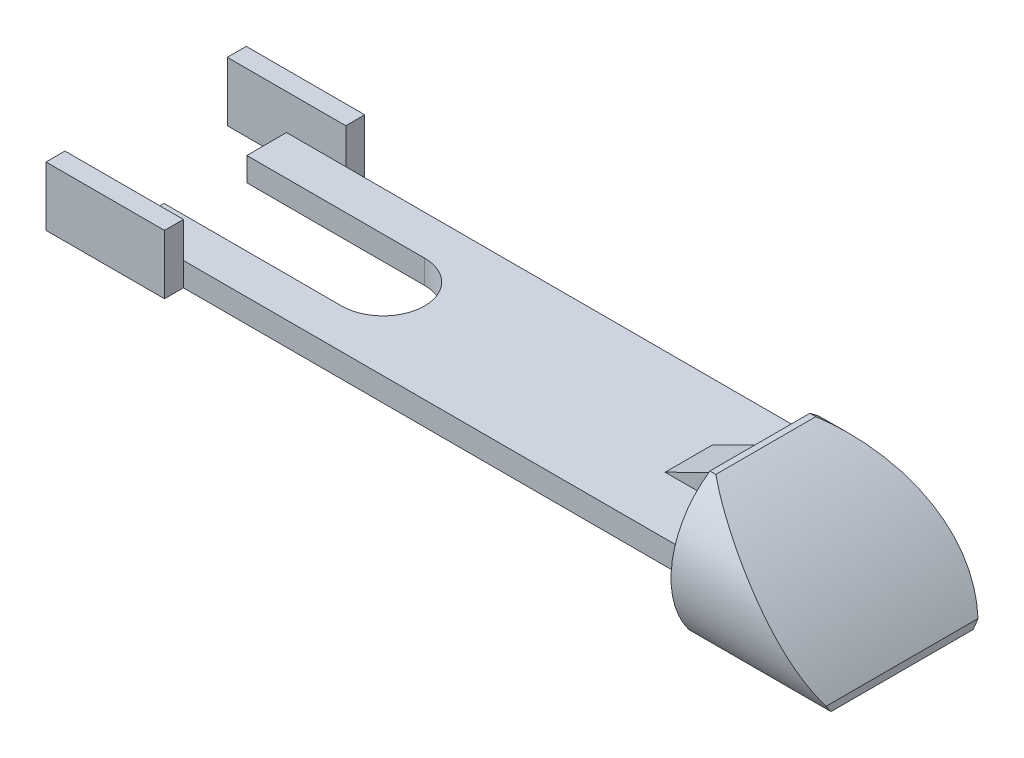
from build123d import *

# Parameters (mm, degrees)
SKETCH1_W               = 59.436
SKETCH1_H               = 17.399
BOSS_EXTRUDE1_DEPTH     = 2.54
CUT_EXTRUDE1_DEPTH      = 32.069155512
SKETCH3_W               = 12.7
SKETCH3_H               = 6.35
BOSS_EXTRUDE2_DEPTH     = 2.032
BOSS_EXTRUDE3_DEPTH     = 15.24
CUT_EXTRUDE2_DEPTH      = 47.886984472
CUT_EXTRUDE2_DEPTH_BACK = 47.886984472
RIB1_REACH              = 48.887
SKETCH6_WALL_W          = 104.28296917
SKETCH6_WALL_H          = 5.08


with BuildPart() as part:
    # Sketch1 → Boss-Extrude1 (new body)
    with BuildSketch(Plane(origin=(0, 0, 0), x_dir=(1, 0, 0), z_dir=(0, 1, 0))):
        Rectangle(SKETCH1_W, SKETCH1_H)
    extrude(amount=BOSS_EXTRUDE1_DEPTH)

    # Sketch2 → Cut-Extrude1 (cut, through all)
    with BuildSketch(Plane(origin=(0, 2.54, 0), x_dir=(1, 0, 0), z_dir=(0, 1, 0))):
        with BuildLine():
            Line((-29.718, 0), (-29.718, 4.445))
            Line((-29.718, 4.445), (-10.668, 4.445))
            ThreePointArc((-10.668, 4.445), (-6.223, 0), (-10.668, -4.445))
            Line((-10.668, -4.445), (-29.718, -4.445))
            Line((-29.718, -4.445), (-29.718, 0))
        make_face()
    extrude(amount=-CUT_EXTRUDE1_DEPTH, mode=Mode.SUBTRACT)

    # Sketch3 → Boss-Extrude2 (add)
    with BuildSketch(Plane.XY.offset(8.6995)):
        with Locations((-29.718, 3.175)):
            Rectangle(SKETCH3_W, SKETCH3_H)
    boss_extrude2 = extrude(amount=BOSS_EXTRUDE2_DEPTH)

    # Mirror1: Boss-Extrude2 across plane
    add(boss_extrude2.mirror(Plane.XY))

    # Sketch4 → Boss-Extrude3 (add)
    with BuildSketch(Plane(origin=(29.718, 0, 0), x_dir=(0, 0, -1), z_dir=(1, 0, 0))):
        with BuildLine():
            Line((-5.3594, 7.874163869), (5.3594, 7.874163869))
            ThreePointArc((5.3594, 7.874163869), (9.395879403, 1.563033987), (7.62, -5.715))
            Line((7.62, -5.715), (-7.62, -5.715))
            ThreePointArc((-7.62, -5.715), (-9.395879403, 1.563033987), (-5.3594, 7.874163869))
        make_face()
    extrude(amount=BOSS_EXTRUDE3_DEPTH)

    # Sketch5 → Cut-Extrude2 (cut, two sides)
    with BuildSketch(Plane.XY) as cut_extrude2_sk:
        with BuildLine():
            Line((-125.410978847, 85.578603758), (30.353, 7.874163869))
            ThreePointArc((30.353, 7.874163869), (38.487292522, 2.407660331), (44.958, -4.953))
            Line((44.958, -4.953), (142.117632376, -149.38430866))
            Line((142.117632376, -149.38430866), (371.853916425, 112.19326708))
            Line((371.853916425, 112.19326708), (104.325305202, 347.156179498))
            Line((104.325305202, 347.156179498), (-125.410978847, 85.578603758))
        make_face()
    extrude(amount=CUT_EXTRUDE2_DEPTH, mode=Mode.SUBTRACT)
    extrude(cut_extrude2_sk.sketch, amount=-CUT_EXTRUDE2_DEPTH_BACK, mode=Mode.SUBTRACT)

    # Sketch6 wall → Rib1 (add, up to next)
    with BuildSketch(Plane(origin=(25.908, 4.433322543, 0), x_dir=(0.895522388061, 0.445016463157, 0), z_dir=(-0.445016463157, 0.895522388061, 0)), mode=Mode.PRIVATE) as rib1_sk1:
        Rectangle(SKETCH6_WALL_W, SKETCH6_WALL_H)
    rib1_tool1 = extrude(rib1_sk1.sketch, amount=-RIB1_REACH, mode=Mode.PRIVATE) - part.part
    add(rib1_tool1.solids().sort_by_distance((25.908, 4.433322543, 0))[0])


solid = part.part
